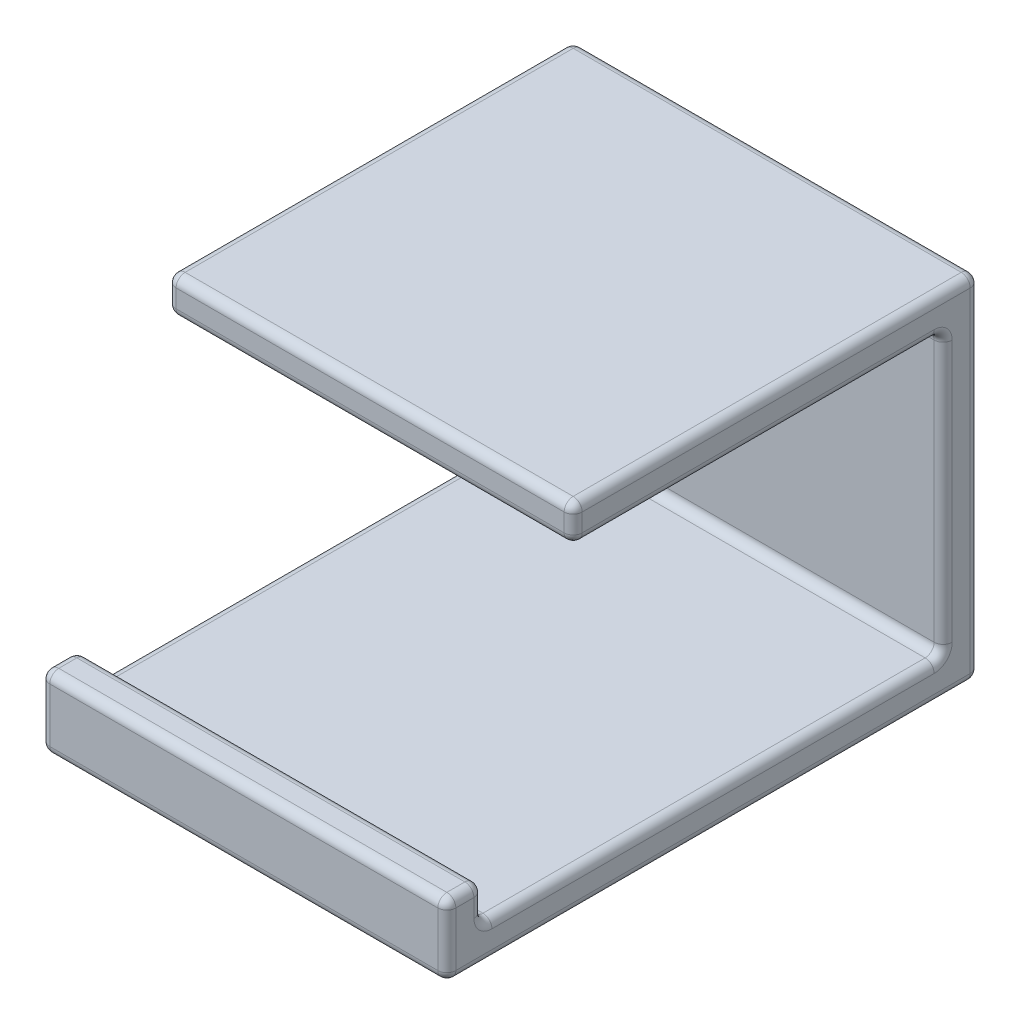
from build123d import *

# Parameters (mm, degrees)
ESBO_O1_W                = 45
ESBO_O1_H                = 35
RESSALTO_EXTRUS_O1_DEPTH = 4
ESBO_O2_W                = 45
ESBO_O2_H                = 45
RESSALTO_EXTRUS_O2_DEPTH = 4
ESBO_O3_W                = 45
ESBO_O3_H                = 4
RESSALTO_EXTRUS_O3_DEPTH = 55
ESBO_O4_W                = 45
ESBO_O4_H                = 4
RESSALTO_EXTRUS_O4_DEPTH = 4
FILETE1_R                = 1


with BuildPart() as part:
    # Esboço1 → Ressalto-extrusão1 (new body)
    with BuildSketch(Plane.XY):
        with Locations((2.182824508, -0.966135458)):
            Rectangle(ESBO_O1_W, ESBO_O1_H)
    extrude(amount=RESSALTO_EXTRUS_O1_DEPTH)

    # Esboço2 → Ressalto-extrusão2 (add)
    with BuildSketch(Plane(origin=(0, 16.533864542, 0), x_dir=(1, 0, 0), z_dir=(0, 1, 0))):
        with Locations((2.182824508, -22.5)):
            Rectangle(ESBO_O2_W, ESBO_O2_H)
    extrude(amount=RESSALTO_EXTRUS_O2_DEPTH)

    # Esboço3 → Ressalto-extrusão3 (add)
    with BuildSketch(Plane.XY.offset(4)):
        with Locations((2.182824508, -16.466135458)):
            Rectangle(ESBO_O3_W, ESBO_O3_H)
    extrude(amount=RESSALTO_EXTRUS_O3_DEPTH)

    # Esboço4 → Ressalto-extrusão4 (add)
    with BuildSketch(Plane(origin=(0, -14.466135458, 0), x_dir=(1, 0, 0), z_dir=(0, 1, 0))):
        with Locations((2.182824508, -57)):
            Rectangle(ESBO_O4_W, ESBO_O4_H)
    extrude(amount=RESSALTO_EXTRUS_O4_DEPTH)

    # Filete1
    filete1_edges = [part.edges().sort_by_distance(p)[0] for p in [
        (-20.317175492, 16.533864542, 24.5),
        (2.182824508, 16.533864542, 45),
        (-20.317175492, 18.533864542, 45),
        (24.682824508, 16.533864542, 24.5),
        (24.682824508, 18.533864542, 45),
        (2.182824508, 16.533864542, 4),
        (-20.317175492, 20.533864542, 22.5),
        (2.182824508, 20.533864542, 45),
        (24.682824508, 20.533864542, 22.5),
        (2.182824508, 20.533864542, 0),
        (24.682824508, 1.033864542, 4),
        (2.182824508, -14.466135458, 4),
        (24.682824508, -14.466135458, 59),
        (-20.317175492, -14.466135458, 59),
        (2.182824508, -18.466135458, 59),
        (-20.317175492, -14.466135458, 29.5),
        (24.682824508, -14.466135458, 29.5),
        (-20.317175492, -12.466135458, 55),
        (2.182824508, -14.466135458, 55),
        (24.682824508, -12.466135458, 55),
        (-20.317175492, -10.466135458, 57),
        (2.182824508, -10.466135458, 59),
        (24.682824508, -10.466135458, 57),
        (2.182824508, -10.466135458, 55),
        (-20.317175492, 1.033864542, 4),
        (24.682824508, 1.033864542, 0),
        (2.182824508, -18.466135458, 0),
        (-20.317175492, 1.033864542, 0),
        (24.682824508, -18.466135458, 29.5),
        (-20.317175492, -18.466135458, 29.5),
    ]]
    fillet(filete1_edges, radius=FILETE1_R)


solid = part.part
